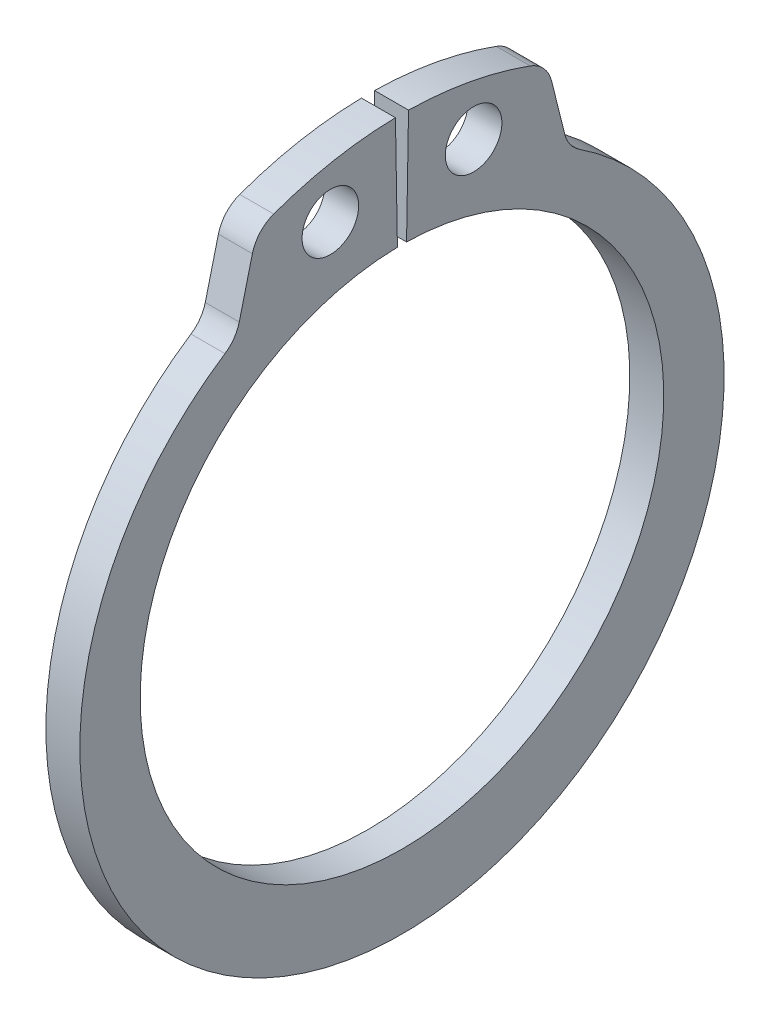
from build123d import *

# Parameters (mm, degrees)
SKETCH1_R      = 1
EXTRUDE1_DEPTH = 0.6
FILLET1_R      = 1.2


with BuildPart() as part:
    # Sketch1 → Extrude1 (new body, symmetric)
    with BuildSketch(Plane(origin=(0, 0, 0), x_dir=(0, 0, -1), z_dir=(1, 0, 0))):
        with BuildLine():
            Line((-0.16143476, 9.24859118), (-0.231244385, 13.247981961))
            ThreePointArc((-0.231244385, 13.247981961), (-2.73314864, 12.965045257), (-5.136358645, 12.213939572))
            Line((-5.136358645, 12.213939572), (-5.866544122, 9.285325583))
            ThreePointArc((-5.866544122, 9.285325583), (0, -11.85), (5.866544122, 9.285325583))
            Line((5.866544122, 9.285325583), (5.136358645, 12.213939572))
            ThreePointArc((5.136358645, 12.213939572), (2.73314864, 12.965045257), (0.231244385, 13.247981961))
            Line((0.231244385, 13.247981961), (0.16143476, 9.24859118))
            ThreePointArc((0.16143476, 9.24859118), (0, -9.25), (-0.16143476, 9.24859118))
        make_face()
        with Locations((-2.53014565, 11.207549834)):
            Circle(SKETCH1_R, mode=Mode.SUBTRACT)
        with Locations((2.53014565, 11.207549834)):
            Circle(SKETCH1_R, mode=Mode.SUBTRACT)
    extrude(amount=EXTRUDE1_DEPTH, both=True)

    # Fillet1
    fillet1_edges = [part.edges().sort_by_distance(p)[0] for p in [
        (0, 12.213939572, -5.136358645),
        (0, 9.285325583, -5.866544122),
        (0, 9.285325583, 5.866544122),
        (0, 12.213939572, 5.136358645),
    ]]
    fillet(fillet1_edges, radius=FILLET1_R)


solid = part.part
